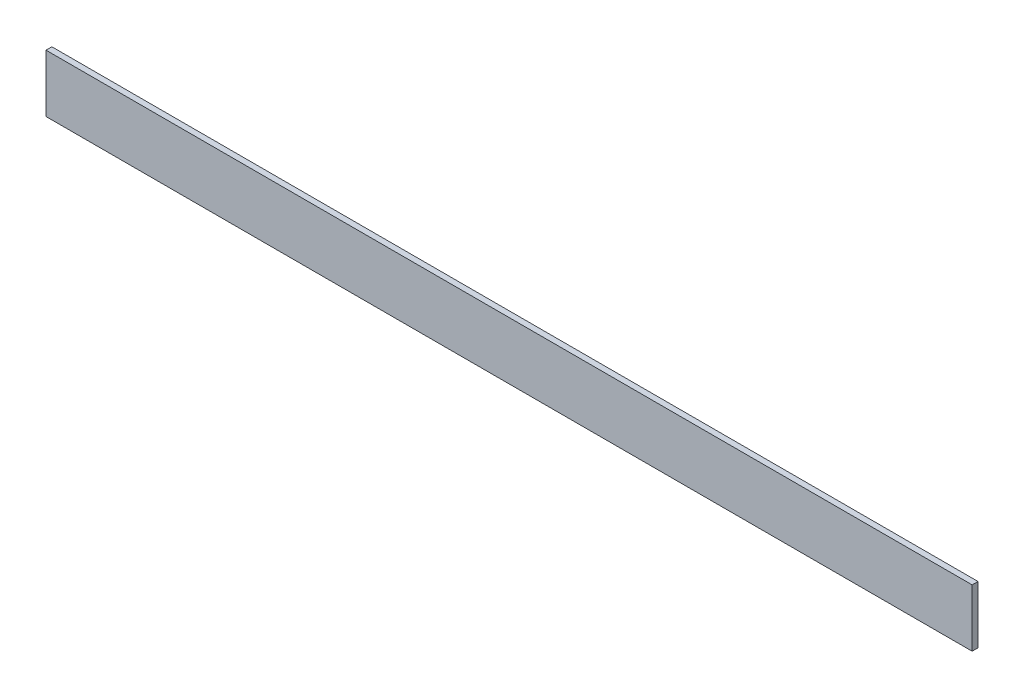
from build123d import *

# Parameters (mm, degrees)
SKETCH_1_W      = 473.33
SKETCH_1_H      = 29.38
EXTRUDE_1_DEPTH = 3


with BuildPart() as part:
    # 草图1 → 凸台-拉伸1 (new body)
    with BuildSketch(Plane.XY):
        Rectangle(SKETCH_1_W, SKETCH_1_H)
    extrude(amount=EXTRUDE_1_DEPTH)


solid = part.part
